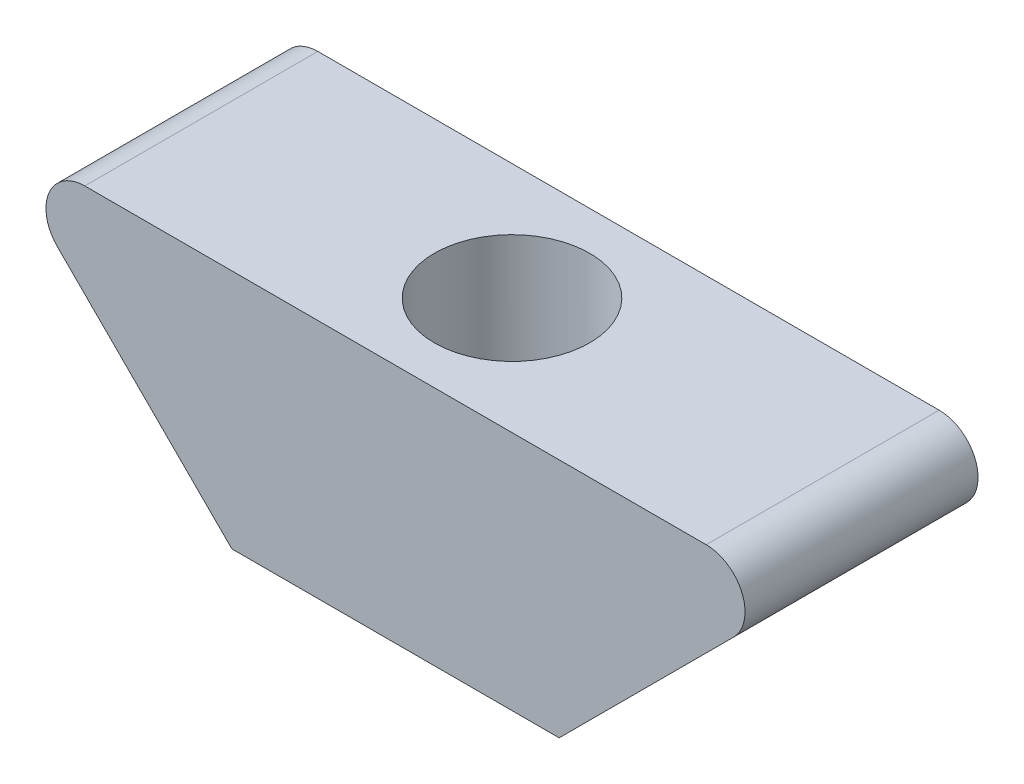
from build123d import *

# Parameters (mm, degrees)
BOSS_EXTRUDE1_DEPTH = 6
SKETCH2_R           = 2
CUT_EXTRUDE1_DEPTH  = 8


with BuildPart() as part:
    # Sketch1 → Boss-Extrude1 (new body)
    with BuildSketch(Plane.XY):
        with BuildLine():
            Line((-8, 3.1), (8, 3.1))
            ThreePointArc((8, 3.1), (8.925, 2.479967104), (8.702939142, 1.38875))
            Line((8.702939142, 1.38875), (4.214189142, -3.1))
            Line((4.214189142, -3.1), (-4.214189142, -3.1))
            Line((-4.214189142, -3.1), (-8.702939142, 1.38875))
            ThreePointArc((-8.702939142, 1.38875), (-8.925, 2.479967104), (-8, 3.1))
        make_face()
    extrude(amount=BOSS_EXTRUDE1_DEPTH)

    # Sketch2 → Cut-Extrude1 (cut)
    with BuildSketch(Plane(origin=(0, 3.1, 0), x_dir=(1, 0, 0), z_dir=(0, 1, 0))):
        with Locations((0, -3)):
            Circle(SKETCH2_R)
    extrude(amount=-CUT_EXTRUDE1_DEPTH, mode=Mode.SUBTRACT)


solid = part.part
